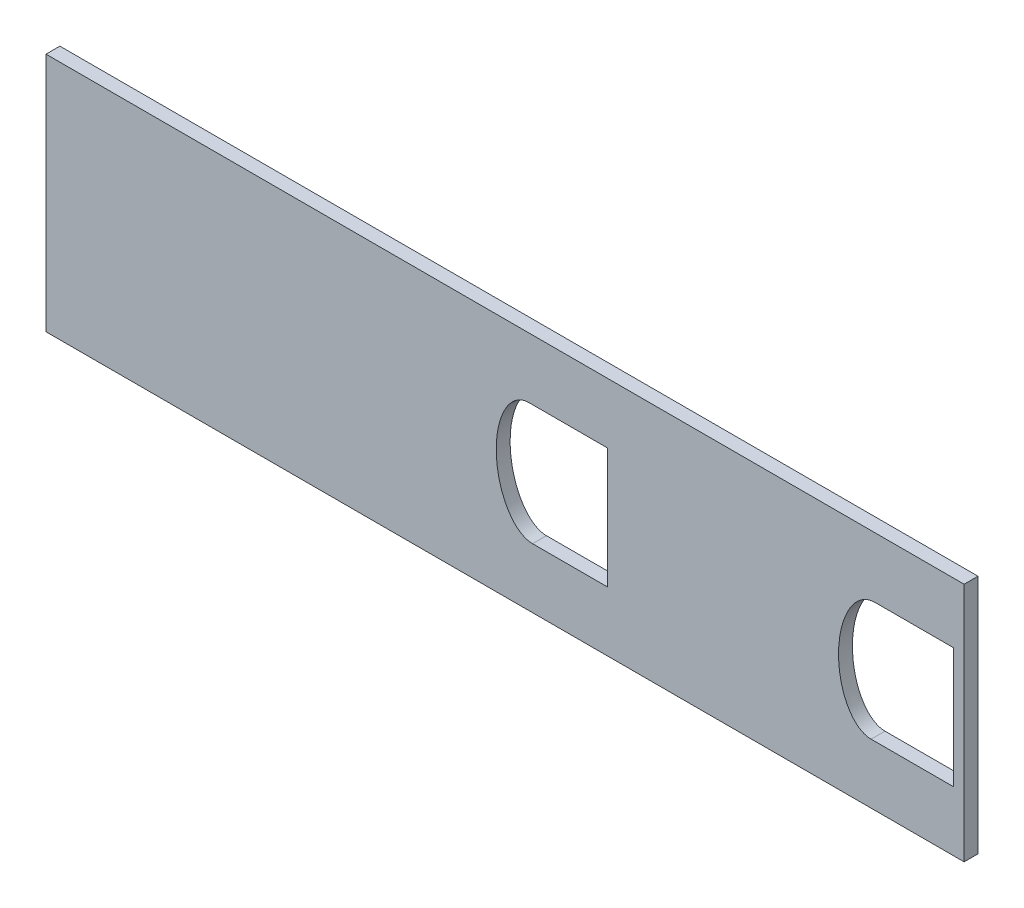
from build123d import *

# Parameters (mm, degrees)
SKETCH1_W           = 210
SKETCH1_H           = 55
BOSS_EXTRUDE2_DEPTH = 3.175


with BuildPart() as part:
    # Sketch1 → Boss-Extrude2 (new body)
    with BuildSketch(Plane.XY):
        with Locations((-261.58829827, -143.616742272)):
            Rectangle(SKETCH1_W, SKETCH1_H)
        with BuildLine():
            Line((-256.126515872, -129.914493968), (-238.126515872, -129.914493968))
            Line((-238.126515872, -129.914493968), (-238.126515872, -157.445143065))
            Line((-238.126515872, -157.445143065), (-255.301947619, -157.445143065))
            add(Edge.make_bspline(
                [(-256.126515872, -129.914493968), (-256.132992045, -129.914493968), (-256.139468965, -129.91450781), (-256.512923163, -129.916105653), (-256.871976666, -129.961276413), (-257.575127126, -130.133923564), (-257.921636069, -130.263410906), (-258.571621418, -130.586176219), (-258.879489776, -130.78021096), (-259.462810842, -131.221200769), (-259.731937947, -131.463068859), (-260.235067773, -131.98012087), (-260.468977829, -132.255392686), (-260.907271385, -132.833942556), (-261.111268678, -133.137182585), (-261.673586312, -134.063668351), (-261.988251583, -134.710018031), (-262.527518193, -136.045634253), (-262.752464397, -136.739423267), (-263.117244618, -138.134526481), (-263.258245033, -138.837666692), (-263.46944613, -140.253506783), (-263.539513018, -140.966224727), (-263.613946735, -142.400531703), (-263.618118635, -143.125138919), (-263.535049841, -145.288890406), (-263.355011587, -146.710051192), (-262.880494808, -148.806791259), (-262.687866041, -149.499806054), (-262.222220804, -150.872074189), (-261.951824884, -151.54335372), (-261.482245138, -152.517058611), (-261.314868687, -152.836389762), (-260.955397443, -153.463120717), (-260.762547685, -153.771633607), (-260.145999628, -154.667359954), (-259.687952955, -155.223199045), (-258.899796605, -155.968133011), (-258.6177264, -156.202737546), (-258.026082675, -156.620875313), (-257.715719206, -156.805710538), (-257.223224925, -157.038052598), (-257.053549951, -157.108271733), (-256.710372006, -157.229384829), (-256.363038305, -157.331581483), (-256.007000457, -157.394158026), (-255.653394629, -157.434931154), (-255.476848891, -157.445143065), (-255.301947619, -157.445143065)],
                knots=[0.999724199, 0.999724199, 0.999724199, 0.999724199, 1, 1, 1.015625, 1.015625, 1.03125, 1.03125, 1.046875, 1.046875, 1.0625, 1.0625, 1.078125, 1.078125, 1.09375, 1.09375, 1.125, 1.125, 1.15625, 1.15625, 1.1875, 1.1875, 1.21875, 1.21875, 1.25, 1.25, 1.3125, 1.3125, 1.34375, 1.34375, 1.375, 1.375, 1.390625, 1.390625, 1.40625, 1.40625, 1.4375, 1.4375, 1.453125, 1.453125, 1.46875, 1.46875, 1.4765625, 1.4765625, 1.484375, 1.4921875, 1.4921875, 1.499694839, 1.499694839, 1.499694839, 1.499694839], degree=3))
        make_face(mode=Mode.SUBTRACT)
        with BuildLine():
            Line((-177.040464824, -129.914493131), (-159.040464824, -129.914493131))
            Line((-159.040464824, -129.914493131), (-159.040464824, -157.445142267))
            Line((-159.040464824, -157.445142267), (-177.864702912, -157.445142267))
            add(Edge.make_bspline(
                [(-177.040464824, -129.914493131), (-177.400259083, -129.914493131), (-177.752698521, -129.956434579), (-178.450508164, -130.118281465), (-178.798446548, -130.241521216), (-179.784142425, -130.703186625), (-180.381814164, -131.138745878), (-181.168722929, -131.880440702), (-181.414752425, -132.143698936), (-181.879762188, -132.696854414), (-182.099643917, -132.988258366), (-182.714813277, -133.884005529), (-183.067807311, -134.509863609), (-183.688975752, -135.804188375), (-183.956661427, -136.472900571), (-184.418821119, -137.847102378), (-184.60922195, -138.540686475), (-185.076516236, -140.637355053), (-185.251107732, -142.05642333), (-185.328407938, -144.213722779), (-185.322641079, -144.939527832), (-185.245543482, -146.373081328), (-185.174539397, -147.084089599), (-184.963362414, -148.493812341), (-184.823302583, -149.192546909), (-184.463885552, -150.575922036), (-184.244647865, -151.261133883), (-183.705821701, -152.611490757), (-183.39185114, -153.263426638), (-182.832888757, -154.195423531), (-182.630581648, -154.499761516), (-182.197133509, -155.079419539), (-181.965897633, -155.355342095), (-181.468748984, -155.873956834), (-181.202924715, -156.116733829), (-180.771061379, -156.449154259), (-180.620764556, -156.555065499), (-180.313366279, -156.750731797), (-179.998412932, -156.931007765), (-179.667152799, -157.078065401), (-179.32695585, -157.20691797), (-179.15114653, -157.262494593), (-178.620859868, -157.396113578), (-178.262764543, -157.442154367), (-177.888298624, -157.445095998), (-177.876505167, -157.445142267), (-177.864702912, -157.445142267)],
                knots=[0.000281563, 0.000281563, 0.000281563, 0.000281563, 0.015625, 0.015625, 0.03125, 0.03125, 0.0625, 0.0625, 0.078125, 0.078125, 0.09375, 0.09375, 0.125, 0.125, 0.15625, 0.15625, 0.1875, 0.1875, 0.25, 0.25, 0.28125, 0.28125, 0.3125, 0.3125, 0.34375, 0.34375, 0.375, 0.375, 0.40625, 0.40625, 0.421875, 0.421875, 0.4375, 0.4375, 0.453125, 0.453125, 0.4609375, 0.4609375, 0.46875, 0.4765625, 0.4765625, 0.484375, 0.484375, 0.5, 0.5, 0.500507651, 0.500507651, 0.500507651, 0.500507651], degree=3))
        make_face(mode=Mode.SUBTRACT)
    extrude(amount=BOSS_EXTRUDE2_DEPTH)


solid = part.part
